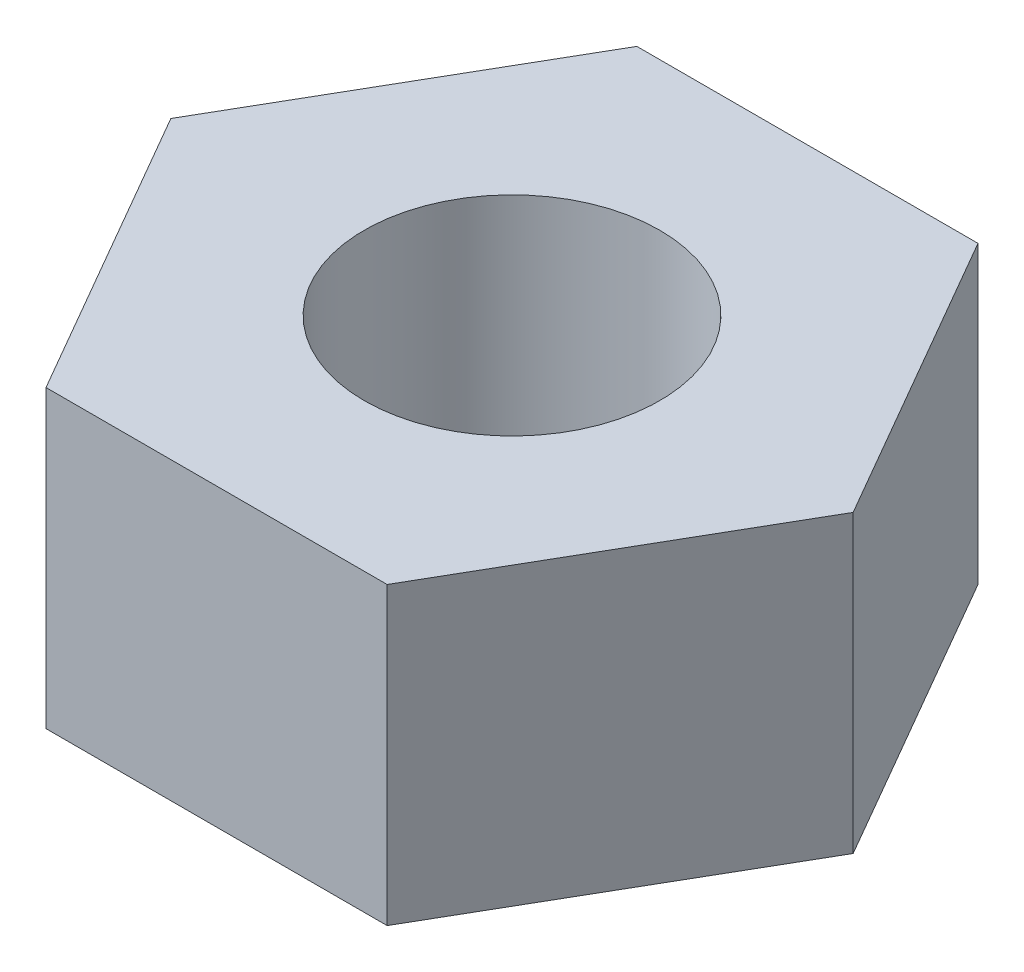
from build123d import *

# Parameters (mm, degrees)
SKETCH1_R           = 2
BOSS_EXTRUDE1_DEPTH = 2


with BuildPart() as part:
    # Sketch1 → Boss-Extrude1 (new body, symmetric)
    with BuildSketch(Plane(origin=(0, 0, 0), x_dir=(1, 0, 0), z_dir=(0, 1, 0))):
        Polygon((2.309401077, 4), (-2.309401077, 4), (-4.618802154, 0), (-2.309401077, -4), (2.309401077, -4), (4.618802154, 0), align=None)
        Circle(SKETCH1_R, mode=Mode.SUBTRACT)
    extrude(amount=BOSS_EXTRUDE1_DEPTH, both=True)


solid = part.part
